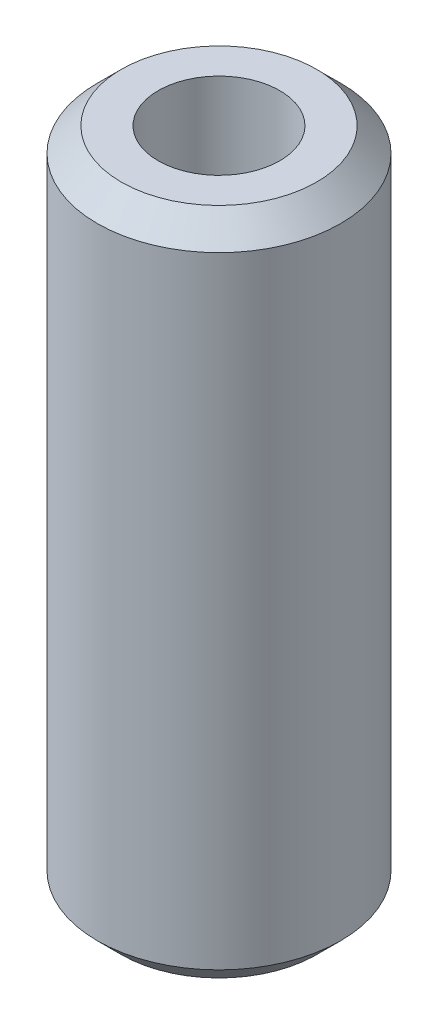
from build123d import *

# Parameters (mm, degrees)
SCHIZZO1_R                   = 12.7
SCHIZZO1_R_2                 = 6.35
ESTRUSIONE_ESTRUSIONE1_DEPTH = 34.925
SMUSSO1_SIZE                 = 2.5


with BuildPart() as part:
    # Schizzo1 → Estrusione-Estrusione1 (new body, symmetric)
    with BuildSketch(Plane(origin=(0, 0, 0), x_dir=(1, 0, 0), z_dir=(0, 1, 0))):
        Circle(SCHIZZO1_R)
        Circle(SCHIZZO1_R_2, mode=Mode.SUBTRACT)
    extrude(amount=ESTRUSIONE_ESTRUSIONE1_DEPTH, both=True)

    # Smusso1
    smusso1_edges = [part.edges().sort_by_distance(p)[0] for p in [
        (-12.7, -34.925, 0),
        (-12.7, 34.925, 0),
    ]]
    chamfer(smusso1_edges, length=SMUSSO1_SIZE)


solid = part.part
